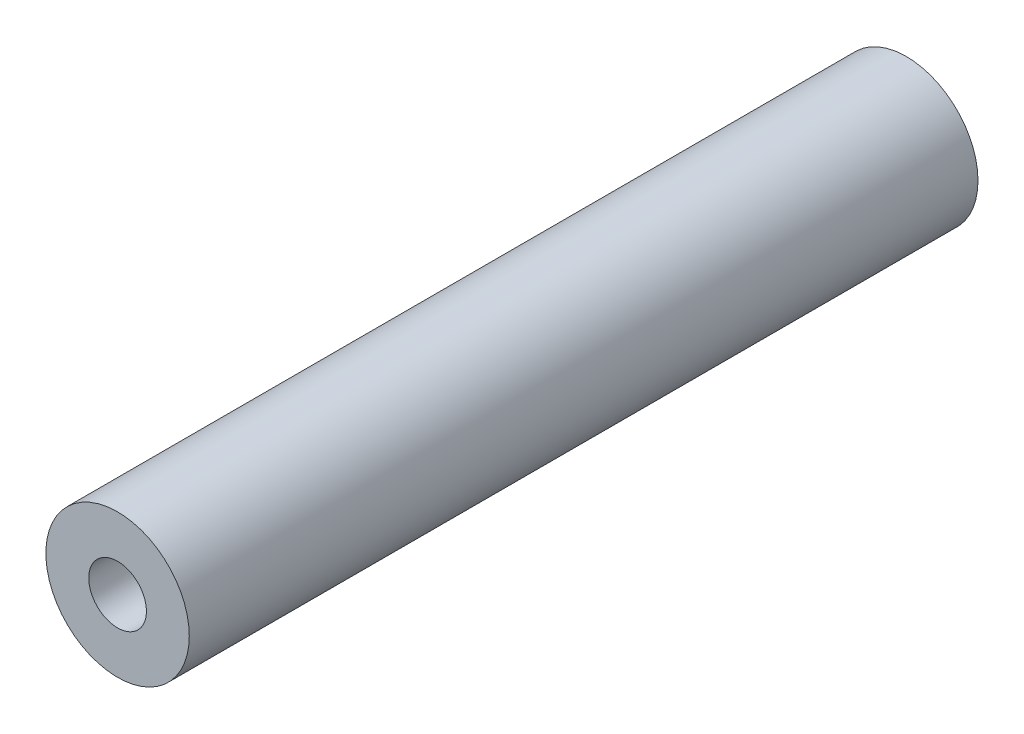
from build123d import *

# Parameters (mm, degrees)
SKIZZE1_R                       = 10
SKIZZE1_R_2                     = 4.025
AUFSATZ_LINEAR_AUSTRAGEN1_DEPTH = 110


with BuildPart() as part:
    # Skizze1 → Aufsatz-Linear austragen1 (new body)
    with BuildSketch(Plane.XY):
        Circle(SKIZZE1_R)
        Circle(SKIZZE1_R_2, mode=Mode.SUBTRACT)
    extrude(amount=AUFSATZ_LINEAR_AUSTRAGEN1_DEPTH)


solid = part.part
